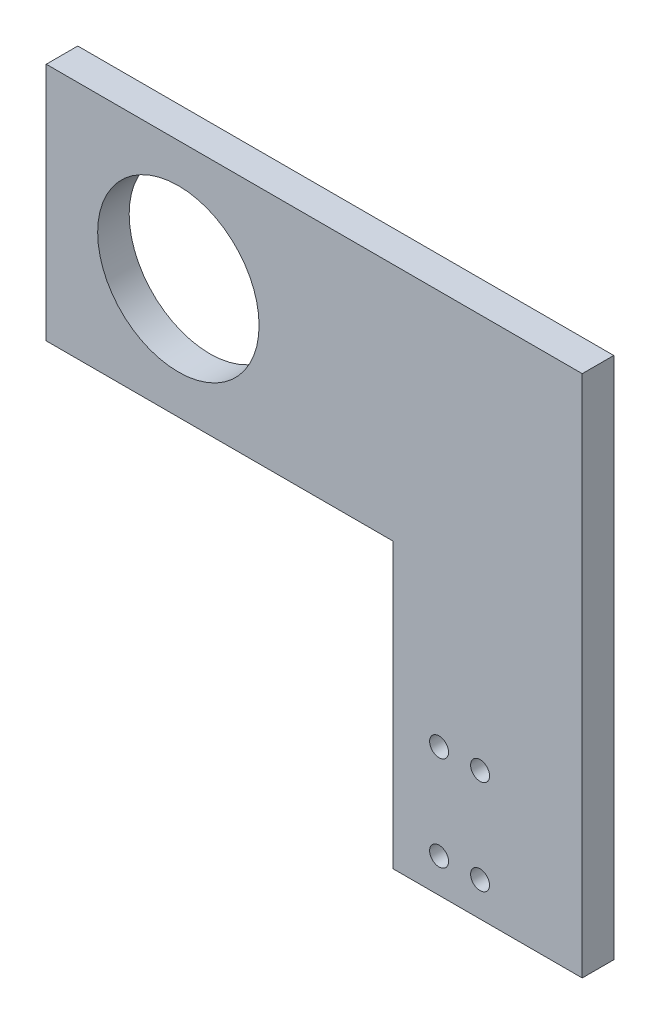
from build123d import *

# Parameters (mm, degrees)
SKETCH_6_R      = 1.5
SKETCH_6_R_2    = 12.8
EXTRUDE_5_DEPTH = 5


with BuildPart() as part:
    # 草图6 → 凸台-拉伸5 (new body)
    with BuildSketch(Plane.XY):
        Polygon((2402.480529225, 4706.107207741), (2402.480529225, 4661.107207741), (2432.480529225, 4661.107207741), (2432.480529225, 4744.107207741), (2347.480529225, 4744.107207741), (2347.480529225, 4706.107207741), align=None)
        with Locations((2409.779347429, 4666.507207741)):
            Circle(SKETCH_6_R, mode=Mode.SUBTRACT)
        with Locations((2409.779347429, 4681.507207741)):
            Circle(SKETCH_6_R, mode=Mode.SUBTRACT)
        with Locations((2416.279347429, 4666.507207741)):
            Circle(SKETCH_6_R, mode=Mode.SUBTRACT)
        with Locations((2416.279347429, 4681.507207741)):
            Circle(SKETCH_6_R, mode=Mode.SUBTRACT)
        with Locations((2368.433509167, 4725.107207741)):
            Circle(SKETCH_6_R_2, mode=Mode.SUBTRACT)
    extrude(amount=EXTRUDE_5_DEPTH)


solid = part.part
